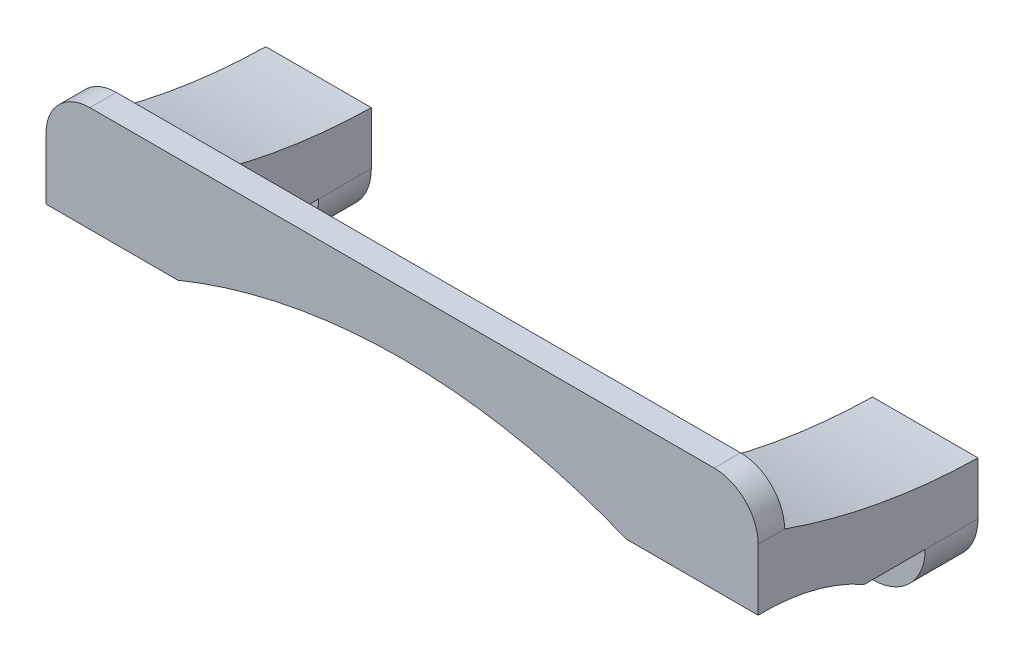
from build123d import *

# Parameters (mm, degrees)
IZIM1_R                       = 6
IZIM1_R_2                     = 1.7
Y_KSEKLIK_EKSTR_ZYON1_DEPTH   = 22
Y_KSEKLIK_EKSTR_ZYON1_2_DEPTH = 22
IZIM2_R                       = 1.7
Y_KSEKLIK_EKSTR_ZYON2_DEPTH   = 3
RADYUS2_R                     = 5
IZIM4_R                       = 1.6
KES_EKSTR_ZYON1_DEPTH         = 10
Y_KSEKLIK_EKSTR_ZYON5_DEPTH   = 12
Y_KSEKLIK_EKSTR_ZYON6_DEPTH   = 12
KES_EKSTR_ZYON2_DEPTH         = 97
IZIM10_W                      = 6.92309327
IZIM10_H                      = 6.61748972
KES_EKSTR_ZYON3_DEPTH         = 97
IZIM11_R                      = 3
KES_EKSTR_ZYON4_DEPTH         = 97
IZIM12_R                      = 1.6
Y_KSEKLIK_EKSTR_ZYON8_DEPTH   = 10
IZIM13_R                      = 1.7
KES_EKSTR_ZYON5_DEPTH         = 10
KES_EKSTR_ZYON6_DEPTH         = 10


with BuildPart() as part:
    # Çizim1 → Yükseklik-Ekstrüzyon1 (new body)
    with BuildSketch(Plane.XY):
        with Locations((34.5, 0)):
            Circle(IZIM1_R)
        with Locations((34.5, 0)):
            Circle(IZIM1_R_2, mode=Mode.SUBTRACT)
    extrude(amount=Y_KSEKLIK_EKSTR_ZYON1_DEPTH)



with BuildPart() as body_2:
    # Çizim1 → Y_kseklik-Ekstr_zyon1 2 (new body)
    with BuildSketch(Plane.XY):
        with Locations((-34.5, 0)):
            Circle(IZIM1_R)
        with Locations((-34.5, 0)):
            Circle(IZIM1_R_2, mode=Mode.SUBTRACT)
    extrude(amount=Y_KSEKLIK_EKSTR_ZYON1_2_DEPTH)


with BuildPart() as part_1:
    add(part.part)

    add(body_2.part)  # Yükseklik-Ekstrüzyon2 merges body 2
    # Çizim2 → Yükseklik-Ekstrüzyon2 (add)
    with BuildSketch(Plane.XY.offset(22)):
        with BuildLine():
            Line((-40.5, 0), (-40.5, 10))
            Line((-40.5, 10), (-40.5, 15))
            Line((-40.5, 15), (40.5, 15))
            Line((40.5, 15), (40.5, 10))
            Line((40.5, 10), (40.5, 0))
            ThreePointArc((40.5, 0), (37.400947284, -5.252095282), (31.305165048, -5.078683848))
            ThreePointArc((31.305165048, -5.078683848), (23.833029749, -2.135860906), (16.017952, -0.287193122))
            ThreePointArc((16.017952, -0.287193122), (8.530102356, 4.184082865), (0, 6))
            ThreePointArc((0, 6), (-8.530102356, 4.184082865), (-16.017952, -0.287193122))
            ThreePointArc((-16.017952, -0.287193122), (-23.833029749, -2.135860906), (-31.305165048, -5.078683848))
            ThreePointArc((-31.305165048, -5.078683848), (-37.400947284, -5.252095282), (-40.5, 0))
        make_face()
        with Locations((-34.5, 0)):
            Circle(IZIM2_R, mode=Mode.SUBTRACT)
        with Locations((34.5, 0)):
            Circle(IZIM2_R, mode=Mode.SUBTRACT)
    extrude(amount=Y_KSEKLIK_EKSTR_ZYON2_DEPTH)

    # Radyus2
    radyus2_edges = [part_1.edges().sort_by_distance(p)[0] for p in [
        (40.5, 15, 23.5),
        (-40.5, 15, 23.5),
    ]]
    fillet(radyus2_edges, radius=RADYUS2_R)

    # Çizim4 → Kes-Ekstrüzyon1 (cut)
    with BuildSketch(Plane.XY.offset(25)):
        with Locations((-35, 5)):
            Circle(IZIM4_R)
        with Locations((35, 5)):
            Circle(IZIM4_R)
    extrude(amount=-KES_EKSTR_ZYON1_DEPTH, mode=Mode.SUBTRACT)

    # Çizim5 → Yükseklik-Ekstrüzyon5 (add)
    with BuildSketch(Plane.ZY.offset(40.5)):
        with BuildLine():
            Line((0, 6), (0, 0))
            Line((0, 0), (22, 0))
            Line((22, 0), (22, 10))
            ThreePointArc((22, 10), (11.160931836, 7.114874904), (0, 6))
        make_face()
    extrude(amount=-Y_KSEKLIK_EKSTR_ZYON5_DEPTH)

    # Çizim6 → Yükseklik-Ekstrüzyon6 (add)
    with BuildSketch(Plane(origin=(40.5, 0, 0), x_dir=(0, 0, -1), z_dir=(1, 0, 0))):
        with BuildLine():
            Line((-22, 0), (-22, 10))
            ThreePointArc((-22, 10), (-11.160931836, 7.114874904), (0, 6))
            Line((0, 6), (0, 0))
            Line((0, 0), (-22, 0))
        make_face()
    extrude(amount=-Y_KSEKLIK_EKSTR_ZYON6_DEPTH)

    # Çizim9 → Kes-Ekstrüzyon2 (cut)
    with BuildSketch(Plane.ZY.offset(40.5)):
        with BuildLine():
            Line((25, 3), (25, -6.889643691))
            Line((25, -6.889643691), (6, -6))
            ThreePointArc((6, -6), (14.421146183, 0.77758028), (25, 3))
        make_face()
    extrude(amount=-KES_EKSTR_ZYON2_DEPTH, mode=Mode.SUBTRACT)

    # Çizim10 → Kes-Ekstrüzyon3 (cut)
    with BuildSketch(Plane.ZY.offset(40.5)):
        with Locations((9.461563543, -3.30874486)):
            Rectangle(IZIM10_W, IZIM10_H)
    extrude(amount=-KES_EKSTR_ZYON3_DEPTH, mode=Mode.SUBTRACT)

    # Çizim11 → Kes-Ekstrüzyon4 (cut)
    with BuildSketch(Plane.XY.offset(6.000016908)):
        with Locations((-34.5, 0)):
            Circle(IZIM11_R)
        with Locations((34.5, 0)):
            Circle(IZIM11_R)
    extrude(amount=KES_EKSTR_ZYON4_DEPTH, mode=Mode.SUBTRACT)

    # Çizim12 → Yükseklik-Ekstrüzyon8 (add)
    with BuildSketch(Plane.XY.offset(25)):
        with Locations((-35, 5)):
            Circle(IZIM12_R)
        with Locations((35, 5)):
            Circle(IZIM12_R)
    extrude(amount=-Y_KSEKLIK_EKSTR_ZYON8_DEPTH)

    # Çizim13 → Kes-Ekstrüzyon5 (cut)
    with BuildSketch(Plane(origin=(0, 0, 0), x_dir=(-1, 0, 0), z_dir=(0, 0, -1))):
        with Locations((34.5, 0)):
            Circle(IZIM13_R)
        with Locations((-34.5, 0)):
            Circle(IZIM13_R)
    extrude(amount=-KES_EKSTR_ZYON5_DEPTH, mode=Mode.SUBTRACT)

    # Çizim15 → Kes-Ekstrüzyon6 (cut)
    with BuildSketch(Plane.XY.offset(25)):
        with BuildLine():
            Line((-25.5, 3), (-25.5, -6.328988838))
            Line((-25.5, -6.328988838), (21.982441761, -11.682646241))
            Line((21.982441761, -11.682646241), (25.5, 3))
            ThreePointArc((25.5, 3), (0, 8.028595904), (-25.5, 3))
        make_face()
    extrude(amount=-KES_EKSTR_ZYON6_DEPTH, mode=Mode.SUBTRACT)


solid = part_1.part
